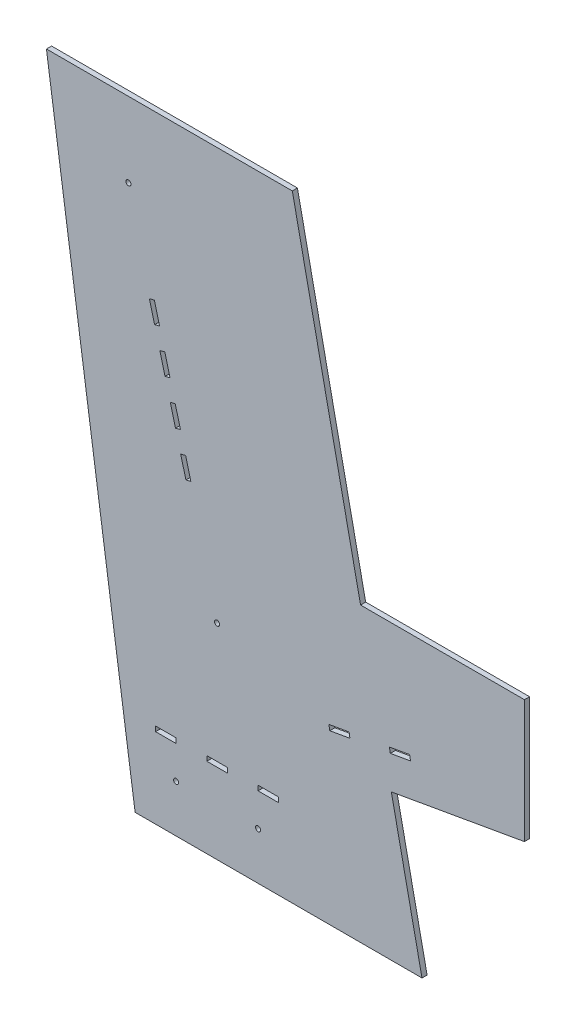
from build123d import *

# Parameters (mm, degrees)
BOSS_EXTRUDE1_DEPTH = 3.175
SKETCH2_R           = 1.5875
CUT_EXTRUDE1_DEPTH  = 3.175
BOSS_EXTRUDE2_DEPTH = 3.175
CUT_EXTRUDE2_DEPTH  = 3.175
CUT_EXTRUDE3_DEPTH  = 10.16
LPATTERN1_COUNT     = 4
LPATTERN1_PITCH     = 25.4
SKETCH6_W           = 12.7
SKETCH6_H           = 3.048
CUT_EXTRUDE4_DEPTH  = 5.08
LPATTERN2_COUNT     = 3
LPATTERN2_PITCH     = 31.75
SKETCH7_R           = 1.5875
CUT_EXTRUDE5_DEPTH  = 19.05


with BuildPart() as part:
    # Sketch1 → Boss-Extrude1 (new body)
    with BuildSketch(Plane.XY):
        Polygon((0, 0), (-177.8, 0), (-232.7656, 382.27), (-80.3656, 382.27), align=None)
    extrude(amount=BOSS_EXTRUDE1_DEPTH)

    # Sketch2 → Cut-Extrude1 (cut)
    with BuildSketch(Plane.XY.offset(3.175)):
        with Locations((-127, 127)):
            Circle(SKETCH2_R)
        with Locations((-181.95798, 335.788)):
            Circle(SKETCH2_R)
    extrude(amount=-CUT_EXTRUDE1_DEPTH, mode=Mode.SUBTRACT)

    # Sketch3 → Boss-Extrude2 (add)
    with BuildSketch(Plane.XY.offset(3.175)):
        Polygon((-63.5, 82.55), (63.5, 104.94352655), (63.5, 181.14352655), (-63.5, 181.14352655), align=None)
    extrude(amount=-BOSS_EXTRUDE2_DEPTH)

    # Sketch4 → Cut-Extrude2 (cut)
    with BuildSketch(Plane.XY.offset(3.175)):
        Polygon((-57.15, 104.14), (-44.642941537, 106.345331856), (-45.194274501, 109.472096472), (-57.701332964, 107.266764616), align=None)
        Polygon((-19.62882461, 110.755995569), (-7.121766147, 112.961327425), (-7.673099111, 116.088092041), (-20.180157574, 113.882760185), align=None)
    extrude(amount=-CUT_EXTRUDE2_DEPTH, mode=Mode.SUBTRACT)

    # Sketch5 → Cut-Extrude3 (cut)
    with BuildSketch(Plane.XY.offset(3.175)):
        Polygon((-148.01334563, 206.830707159), (-144.780523225, 194.549059903), (-143.245317319, 194.953162704), (-146.478139723, 207.234809959), align=None)
        Polygon((-146.315729132, 194.144957103), (-144.780523225, 194.549059903), (-148.01334563, 206.830707159), (-149.548551537, 206.426604358), align=None)
    cut_extrude3 = extrude(amount=-CUT_EXTRUDE3_DEPTH, mode=Mode.SUBTRACT)

    # LPattern1: Cut-Extrude3 ×4
    with Locations(*[Vector(-0.254552945, 0.967058839, 0) * (i * LPATTERN1_PITCH) for i in range(1, LPATTERN1_COUNT)]):
        add(cut_extrude3, mode=Mode.SUBTRACT)

    # Sketch6 → Cut-Extrude4 (cut)
    with BuildSketch(Plane.XY.offset(3.175)):
        with Locations((-158.75, 51.181)):
            Rectangle(SKETCH6_W, SKETCH6_H)
    cut_extrude4 = extrude(amount=-CUT_EXTRUDE4_DEPTH, mode=Mode.SUBTRACT)

    # LPattern2: Cut-Extrude4 ×3
    with Locations(*[(i * LPATTERN2_PITCH, 0, 0) for i in range(1, LPATTERN2_COUNT)]):
        add(cut_extrude4, mode=Mode.SUBTRACT)

    # Sketch7 → Cut-Extrude5 (cut)
    with BuildSketch(Plane.XY.offset(3.175)):
        with Locations((-152.4, 29.337)):
            Circle(SKETCH7_R)
        with Locations((-101.6, 29.337)):
            Circle(SKETCH7_R)
    extrude(amount=-CUT_EXTRUDE5_DEPTH, mode=Mode.SUBTRACT)


solid = part.part
